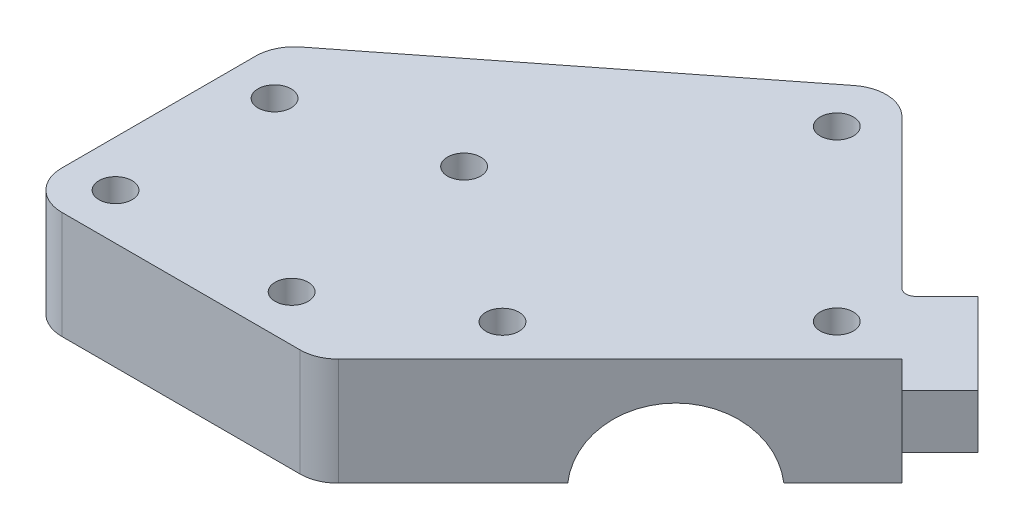
from build123d import *

# Parameters (mm, degrees)
EXTRUDE_1_DEPTH        = 14
EXTRUDE_2_DEPTH        = 7
CUT_EXTRUDE_1_DEPTH    = 38.1
CUT_EXTRUDE_2_DEPTH    = 41.028932188
HOLE_WIZARD_M4_1_D     = 4.318
HOLE_WIZARD_M4_1_DEPTH = 14
FILLET_1_R             = 5
FILLET_3_R             = 1.27
FILLET_4_R             = 1.27


with BuildPart() as part:
    # 草图1 → 凸台-拉伸1 (new body)
    with BuildSketch(Plane.XZ.offset(-1)):
        Polygon((4.743453393, -52.27499012), (35.219755662, -21.79868785), (-2.928932188, 16.35), (-41.028932188, 16.35), (-41.028932188, -16.35), align=None)
    extrude(amount=-EXTRUDE_1_DEPTH)

    # 草图2 → 凸台-拉伸2 (add)
    with BuildSketch(Plane(origin=(0, 15, 0), x_dir=(1, 0, 0), z_dir=(0, 1, 0))):
        Polygon((35.219755662, 21.79868785), (38.755289568, 18.263153944), (43.705037037, 23.212901413), (33.098435319, 33.819503131), (28.14868785, 28.869755662), align=None)
    extrude(amount=-EXTRUDE_2_DEPTH)

    # 草图3 → 切除-拉伸1 (cut)
    with BuildSketch(Plane(origin=(6.710533906, 0, 6.710533906), x_dir=(0.707106781, 0, -0.707106781), z_dir=(0.707106781, 0, 0.707106781))):
        with BuildLine():
            Line((9.538251542, 1), (29.445830798, 1))
            ThreePointArc((29.445830798, 1), (19.49204117, 10.039754177), (9.538251542, 1))
        make_face()
    extrude(amount=-CUT_EXTRUDE_1_DEPTH, mode=Mode.SUBTRACT)

    # 草图4 → 切除-拉伸2 (cut)
    with BuildSketch(Plane.ZY.offset(41.028932188)):
        with BuildLine():
            Line((-6.270765504, 1), (5.579500015, 1))
            ThreePointArc((5.579500015, 1), (-0.345632744, 6.05511811), (-6.270765504, 1))
        make_face()
    extrude(amount=-CUT_EXTRUDE_2_DEPTH, mode=Mode.SUBTRACT)

    # M4 间隙孔1
    with Locations(Plane(origin=(0, 15, 0), x_dir=(1, 0, 0), z_dir=(0, 1, 0))):
        with Locations((-35.028932188, -10.35), (5, 0), (-15, 15), (-12.103043109, -10.35), (-35.028932188, 10.35), (4.743453393, 43.789708745), (26.734474288, 21.79868785)):
            Hole(HOLE_WIZARD_M4_1_D / 2, depth=HOLE_WIZARD_M4_1_DEPTH)

    # 圆角1
    fillet_1_edges = [part.edges().sort_by_distance(p)[0] for p in [
        (-41.028932188, 8, -16.35),
        (-41.028932188, 8, 16.35),
        (-2.928932188, 8, 16.35),
        (4.743453393, 8, -52.27499012),
    ]]
    fillet(fillet_1_edges, radius=FILLET_1_R)

    # 圆角3
    fillet_3_edges = [part.edges().sort_by_distance(p)[0] for p in [
        (28.14868785, 11.5, -28.869755662),
    ]]
    fillet(fillet_3_edges, radius=FILLET_3_R)

    # 圆角4
    fillet_4_edges = [part.edges().sort_by_distance(p)[0] for p in [
        (31.684221756, 8, -25.334221756),
    ]]
    fillet(fillet_4_edges, radius=FILLET_4_R)


solid = part.part
